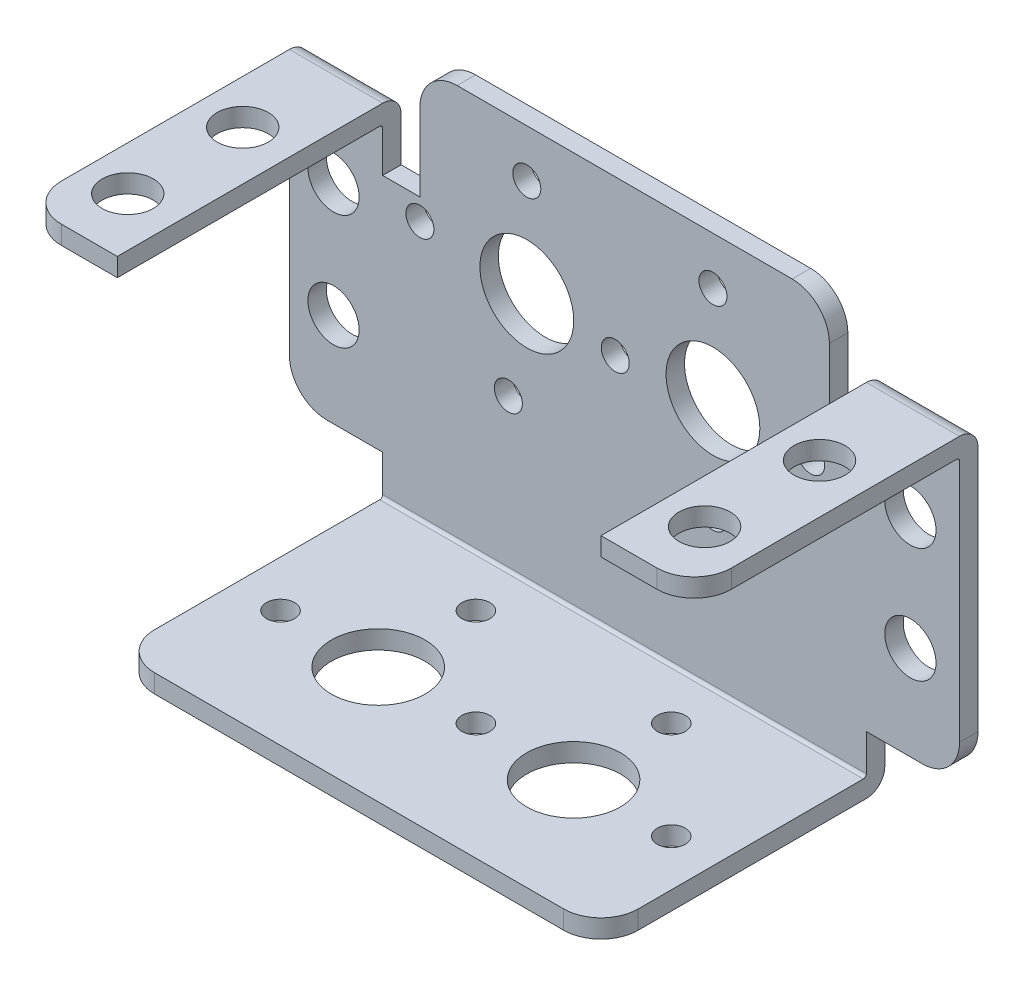
from build123d import *

# Parameters (mm, degrees)
SKETCH1_R      = 4.0005
SKETCH1_R_2    = 1.1938
SKETCH1_R_3    = 2.1844
EXTRUDE2_DEPTH = 1.5748
SKETCH3_W      = 7.9502
SKETCH3_H      = 1.5748
SKETCH3_W_2    = 41.2496
EXTRUDE3_DEPTH = 22.6314
FILLET1_R      = 3.175
FILLET2_R      = 1.5748
FILLET3_R      = 0.254
SKETCH4_R      = 4.0005
SKETCH4_R_2    = 1.1938
EXTRUDE4_DEPTH = 1.5748
SKETCH5_R      = 2.1844
EXTRUDE5_DEPTH = 1.5748


with BuildPart() as part:
    # Sketch1 → Extrude2 (new body)
    with BuildSketch(Plane.XY):
        with BuildLine():
            Line((11.9126, 30.734), (11.9126, 32.041994716))
            ThreePointArc((11.9126, 32.041994716), (12.84253597, 34.287058746), (15.0876, 35.216994716))
            Line((15.0876, 35.216994716), (43.6626, 35.216994716))
            ThreePointArc((43.6626, 35.216994716), (45.90766403, 34.287058746), (46.8376, 32.041994716))
            Line((46.8376, 32.041994716), (46.8376, 30.734))
            Line((46.8376, 30.734), (46.8376, 25.4))
            Line((46.8376, 25.4), (49.9872, 25.4))
            Line((49.9872, 25.4), (49.9872, 30.734))
            Line((49.9872, 30.734), (57.9374, 30.734))
            Line((57.9374, 30.734), (57.9374, 8.128))
            ThreePointArc((57.9374, 8.128), (57.00746403, 5.88293597), (54.7624, 4.953))
            Line((54.7624, 4.953), (49.9872, 4.953))
            Line((49.9872, 4.953), (49.9872, 0))
            Line((49.9872, 0), (8.7376, 0))
            Line((8.7376, 0), (8.7376, 4.953))
            Line((8.7376, 4.953), (3.9624, 4.953))
            ThreePointArc((3.9624, 4.953), (1.71733597, 5.88293597), (0.7874, 8.128))
            Line((0.7874, 8.128), (0.7874, 30.734))
            Line((0.7874, 30.734), (8.7376, 30.734))
            Line((8.7376, 30.734), (8.7376, 25.4))
            Line((8.7376, 25.4), (11.9126, 25.4))
            Line((11.9126, 25.4), (11.9126, 30.734))
        make_face()
        with Locations((21.0312, 22.8092)):
            Circle(SKETCH1_R, mode=Mode.SUBTRACT)
        with Locations((21.0312, 31.1404)):
            Circle(SKETCH1_R_2, mode=Mode.SUBTRACT)
        with Locations((28.575, 22.0218)):
            Circle(SKETCH1_R_2, mode=Mode.SUBTRACT)
        with Locations((19.4564, 14.478)):
            Circle(SKETCH1_R_2, mode=Mode.SUBTRACT)
        with Locations((11.9126, 23.5966)):
            Circle(SKETCH1_R_2, mode=Mode.SUBTRACT)
        with Locations((36.9062, 31.1404)):
            Circle(SKETCH1_R_2, mode=Mode.SUBTRACT)
        with Locations((45.2374, 22.8092)):
            Circle(SKETCH1_R_2, mode=Mode.SUBTRACT)
        with Locations((36.9062, 22.8092)):
            Circle(SKETCH1_R, mode=Mode.SUBTRACT)
        with Locations((36.9062, 14.478)):
            Circle(SKETCH1_R_2, mode=Mode.SUBTRACT)
        with Locations((4.5466, 22.7838)):
            Circle(SKETCH1_R_3, mode=Mode.SUBTRACT)
        with Locations((4.5466, 12.9794)):
            Circle(SKETCH1_R_3, mode=Mode.SUBTRACT)
        with Locations((53.7464, 22.7838)):
            Circle(SKETCH1_R_3, mode=Mode.SUBTRACT)
        with Locations((53.7464, 12.9794)):
            Circle(SKETCH1_R_3, mode=Mode.SUBTRACT)
    extrude(amount=EXTRUDE2_DEPTH)

    # Sketch3 → Extrude3 (add)
    with BuildSketch(Plane.XY.offset(1.5748)):
        with Locations((4.7625, 29.9466)):
            Rectangle(SKETCH3_W, SKETCH3_H)
        with Locations((29.3624, 0.7874)):
            Rectangle(SKETCH3_W_2, SKETCH3_H)
        with Locations((53.9623, 29.9466)):
            Rectangle(SKETCH3_W, SKETCH3_H)
    extrude(amount=EXTRUDE3_DEPTH)

    # Fillet1
    fillet1_edges = [part.edges().sort_by_distance(p)[0] for p in [
        (0.7874, 29.9466, 24.2062),
        (8.7376, 0.7874, 24.2062),
        (49.9872, 0.7874, 24.2062),
        (57.9374, 29.9466, 24.2062),
    ]]
    fillet(fillet1_edges, radius=FILLET1_R)

    # Fillet2
    fillet2_edges = [part.edges().sort_by_distance(p)[0] for p in [
        (4.7625, 30.734, 0),
        (53.9623, 30.734, 0),
        (29.3624, 0, 0),
    ]]
    fillet(fillet2_edges, radius=FILLET2_R)

    # Fillet3
    fillet3_edges = [part.edges().sort_by_distance(p)[0] for p in [
        (4.7625, 29.1592, 1.5748),
        (29.3624, 1.5748, 1.5748),
        (53.9623, 29.1592, 1.5748),
    ]]
    fillet(fillet3_edges, radius=FILLET3_R)

    # Sketch4 → Extrude4 (cut)
    with BuildSketch(Plane.XZ):
        with Locations(Location((21.0312, 14.2494, 0), (0, 0, 270))):  # turned: the seam where the file's is
            Circle(SKETCH4_R)
        with Locations(Location((12.7, 14.2494, 0), (0, 0, 270))):  # turned: the seam where the file's is
            Circle(SKETCH4_R_2)
        with Locations(Location((21.0312, 5.9182, 0), (0, 0, 270))):  # turned: the seam where the file's is
            Circle(SKETCH4_R_2)
        with Locations(Location((29.3624, 14.2494, 0), (0, 0, 270))):  # turned: the seam where the file's is
            Circle(SKETCH4_R_2)
        with Locations(Location((46.0248, 14.2494, 0), (0, 0, 270))):  # turned: the seam where the file's is
            Circle(SKETCH4_R_2)
        with Locations(Location((37.6936, 14.2494, 0), (0, 0, 270))):  # turned: the seam where the file's is
            Circle(SKETCH4_R)
        with Locations(Location((37.6936, 5.9182, 0), (0, 0, 270))):  # turned: the seam where the file's is
            Circle(SKETCH4_R_2)
    extrude(amount=-EXTRUDE4_DEPTH, mode=Mode.SUBTRACT)

    # Sketch5 → Extrude5 (cut)
    with BuildSketch(Plane(origin=(0, 30.734, 0), x_dir=(1, 0, 0), z_dir=(0, 1, 0))):
        with Locations(Location((4.5466, -9.3218, 0), (0, 0, 270))):  # turned: the seam where the file's is
            Circle(SKETCH5_R)
        with Locations(Location((4.5466, -19.1262, 0), (0, 0, 270))):  # turned: the seam where the file's is
            Circle(SKETCH5_R)
        with Locations(Location((53.7464, -19.1262, 0), (0, 0, 270))):  # turned: the seam where the file's is
            Circle(SKETCH5_R)
        with Locations(Location((53.7464, -9.3218, 0), (0, 0, 270))):  # turned: the seam where the file's is
            Circle(SKETCH5_R)
    extrude(amount=-EXTRUDE5_DEPTH, mode=Mode.SUBTRACT)


solid = part.part
